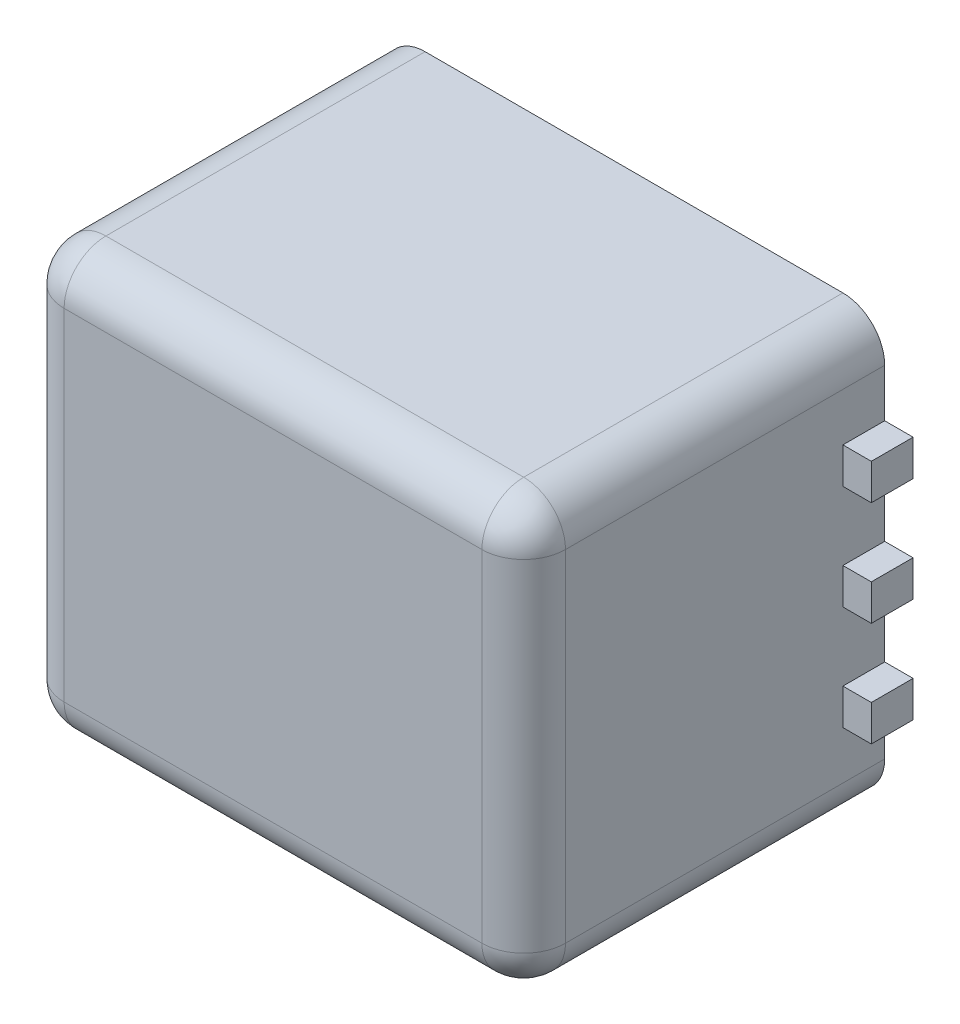
from build123d import *

# Parameters (mm, degrees)
SKETCH1_W           = 12
SKETCH1_H           = 10.16
BOSS_EXTRUDE1_DEPTH = 8.64
FILLET1_R           = 1
SKETCH2_W           = 3.359416773
SKETCH2_H           = 0.86
BOSS_EXTRUDE2_DEPTH = 1


with BuildPart() as part:
    # Sketch1 → Boss-Extrude1 (new body)
    with BuildSketch(Plane.XY):
        with Locations((6, 5.08)):
            Rectangle(SKETCH1_W, SKETCH1_H)
    extrude(amount=BOSS_EXTRUDE1_DEPTH)

    # Fillet1
    fillet1_edges = [part.edges().sort_by_distance(p)[0] for p in [
        (12, 5.08, 8.64),
        (6, 10.16, 8.64),
        (0, 5.08, 8.64),
        (0, 10.16, 4.32),
        (12, 10.16, 4.32),
        (12, 0, 4.32),
        (0, 0, 4.32),
        (6, 0, 8.64),
    ]]
    fillet(fillet1_edges, radius=FILLET1_R)

    # Sketch2 → Boss-Extrude2 (add)
    with BuildSketch(Plane(origin=(0, 0, 0), x_dir=(-1, 0, 0), z_dir=(0, 0, -1))):
        with Locations((-11.000291613, 7.58)):
            Rectangle(SKETCH2_W, SKETCH2_H)
        with Locations((-11.000291613, 5.08)):
            Rectangle(SKETCH2_W, SKETCH2_H)
        with Locations((-11.000291613, 2.58)):
            Rectangle(SKETCH2_W, SKETCH2_H)
        with Locations((-0.999708387, 7.58)):
            Rectangle(SKETCH2_W, SKETCH2_H)
        with Locations((-0.999708387, 5.08)):
            Rectangle(SKETCH2_W, SKETCH2_H)
        with Locations((-0.999708387, 2.58)):
            Rectangle(SKETCH2_W, SKETCH2_H)
    extrude(amount=-BOSS_EXTRUDE2_DEPTH)


solid = part.part
